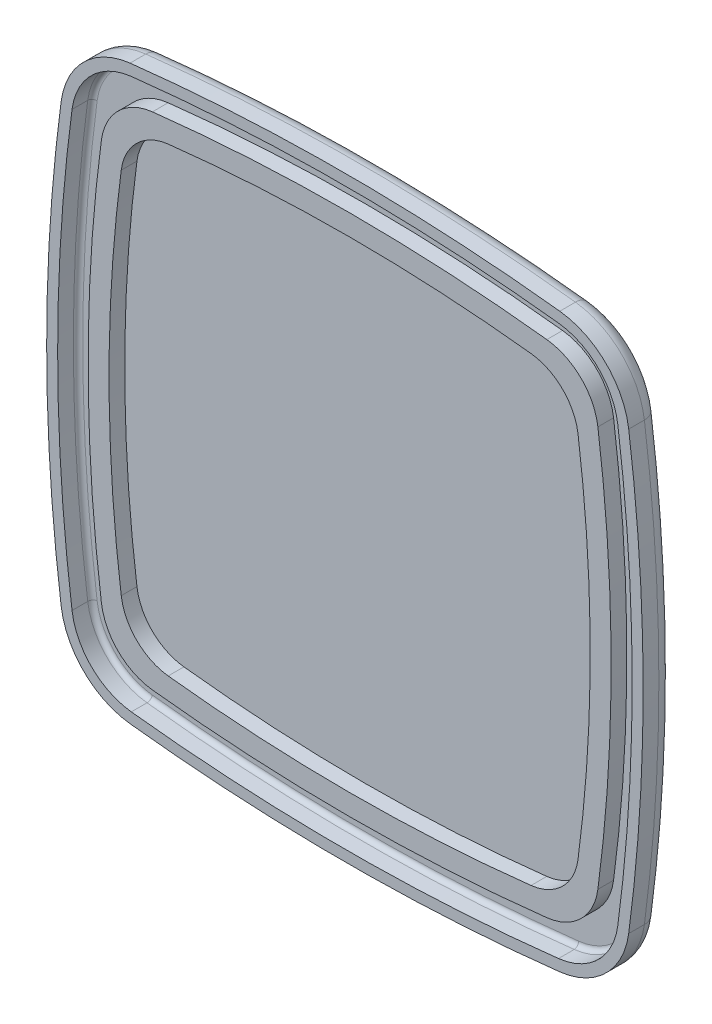
from build123d import *

# Parameters (mm, degrees)
IZIM1_W                      = 38
IZIM1_H                      = 38
Y_KSEKLIK_EKSTR_ZYON1_DEPTH  = 1
KES_EKSTR_ZYON1_DEPTH        = 3
KES_EKSTR_ZYON2_DEPTH        = 3
RADYUS1_R                    = 5
RADYUS2_R                    = 1
BO_ALTMA1_T                  = -0.7
Y_KSEKLIK_EKSTR_ZYON10_DEPTH = 1
KES_EKSTR_ZYON7_DEPTH        = 1


with BuildPart() as part:
    # Çizim1 → Yükseklik-Ekstrüzyon1 (new body, symmetric)
    with BuildSketch(Plane.XY):
        Rectangle(IZIM1_W, IZIM1_H)
    extrude(amount=Y_KSEKLIK_EKSTR_ZYON1_DEPTH, both=True)

    # Çizim2 → Kes-Ekstrüzyon1 (cut, through all)
    with BuildSketch(Plane.XY.offset(1)):
        with BuildLine():
            Line((19, 19), (0, 19))
            ThreePointArc((0, 19), (9.529559276, 18.624417499), (19, 17.5))
            Line((19, 17.5), (19, 19))
        make_face()
        with BuildLine():
            Line((0, 19), (-19, 19))
            Line((-19, 19), (-19, 17.5))
            ThreePointArc((-19, 17.5), (-9.529559276, 18.624417499), (0, 19))
        make_face()
        with BuildLine():
            ThreePointArc((0, -19), (-9.529559276, -18.624417499), (-19, -17.5))
            Line((-19, -17.5), (-19, -19))
            Line((-19, -19), (0, -19))
        make_face()
        with BuildLine():
            Line((19, -19), (19, -17.5))
            ThreePointArc((19, -17.5), (9.529559276, -18.624417499), (0, -19))
            Line((0, -19), (19, -19))
        make_face()
    extrude(amount=-KES_EKSTR_ZYON1_DEPTH, mode=Mode.SUBTRACT)

    # Çizim3 → Kes-Ekstrüzyon2 (cut, through all)
    with BuildSketch(Plane.XY.offset(1)):
        with BuildLine():
            Line((19, 0), (19, 17.5))
            ThreePointArc((19, 17.5), (18.250358245, 17.61670023), (17.5, 17.728701167))
            ThreePointArc((17.5, 17.728701167), (18.624331272, 8.896022216), (19, 0))
        make_face()
        with BuildLine():
            Line((19, -17.5), (19, 0))
            ThreePointArc((19, 0), (18.624331272, -8.896022216), (17.5, -17.728701167))
            ThreePointArc((17.5, -17.728701167), (18.250358245, -17.61670023), (19, -17.5))
        make_face()
        with BuildLine():
            ThreePointArc((-19, -17.5), (-18.250358245, -17.61670023), (-17.5, -17.728701167))
            ThreePointArc((-17.5, -17.728701167), (-18.624331272, -8.896022216), (-19, 0))
            Line((-19, 0), (-19, -17.5))
        make_face()
        with BuildLine():
            ThreePointArc((-19, 0), (-18.624331272, 8.896022216), (-17.5, 17.728701167))
            ThreePointArc((-17.5, 17.728701167), (-18.250358245, 17.61670023), (-19, 17.5))
            Line((-19, 17.5), (-19, 0))
        make_face()
    extrude(amount=-KES_EKSTR_ZYON2_DEPTH, mode=Mode.SUBTRACT)

    # Radyus1
    radyus1_edges = [part.edges().sort_by_distance(p)[0] for p in [
        (17.5, 17.728701167, 0),
        (17.5, -17.728701167, 0),
        (-17.5, -17.728701167, 0),
        (-17.5, 17.728701167, 0),
    ]]
    fillet(radyus1_edges, radius=RADYUS1_R)

    # Radyus2
    radyus2_edges = [part.edges().sort_by_distance(p)[0] for p in [
        (-19, 0, -1),
        (0, -19, -1),
        (0, 19, -1),
        (19, 0, -1),
        (16.62392767, 16.824874803, -1),
        (-16.62392767, 16.824874803, -1),
        (16.62392767, -16.824874803, -1),
        (-16.62392767, -16.824874803, -1),
    ]]
    fillet(radyus2_edges, radius=RADYUS2_R)

    # İç Boşaltma1
    bo_altma1_openings = [part.faces().sort_by_distance(p)[0] for p in [
        (0, 0, 1),
    ]]
    offset(amount=BO_ALTMA1_T, openings=bo_altma1_openings)


with BuildPart() as body_2:
    # Çizim10 → Yükseklik-Ekstrüzyon10 (new body)
    with BuildSketch(Plane.XY.offset(-0.3)):
        with BuildLine():
            ThreePointArc((12.563728068, 15.947604972), (0, 16.65999216), (-12.563728068, 15.947604972))
            ThreePointArc((-12.563728068, 15.947604972), (-14.738134647, 14.911702064), (-15.815114277, 12.757345157))
            ThreePointArc((-15.815114277, 12.757345157), (-16.65999216, 0), (-15.815114277, -12.757345157))
            ThreePointArc((-15.815114277, -12.757345157), (-14.738134647, -14.911702064), (-12.563728068, -15.947604972))
            ThreePointArc((-12.563728068, -15.947604972), (0, -16.65999216), (12.563728068, -15.947604972))
            ThreePointArc((12.563728068, -15.947604972), (14.738134647, -14.911702064), (15.815114277, -12.757345157))
            ThreePointArc((15.815114277, -12.757345157), (16.65999216, 0), (15.815114277, 12.757345157))
            ThreePointArc((15.815114277, 12.757345157), (14.738134647, 14.911702064), (12.563728068, 15.947604972))
        make_face()
    extrude(amount=Y_KSEKLIK_EKSTR_ZYON10_DEPTH)

    # Çizim15 → Kes-Ekstrüzyon7 (cut)
    with BuildSketch(Plane.XY.offset(0.7)):
        with BuildLine():
            ThreePointArc((14.549905135, 11.736757544), (13.559083875, 13.718765899), (11.558629822, 14.671796574))
            ThreePointArc((11.558629822, 14.671796574), (0, 15.327192787), (-11.558629822, 14.671796574))
            ThreePointArc((-11.558629822, 14.671796574), (-13.559083875, 13.718765899), (-14.549905135, 11.736757544))
            ThreePointArc((-14.549905135, 11.736757544), (-15.327192787, 0), (-14.549905135, -11.736757544))
            ThreePointArc((-14.549905135, -11.736757544), (-13.559083875, -13.718765899), (-11.558629822, -14.671796574))
            ThreePointArc((-11.558629822, -14.671796574), (0, -15.327192787), (11.558629822, -14.671796574))
            ThreePointArc((11.558629822, -14.671796574), (13.559083875, -13.718765899), (14.549905135, -11.736757544))
            ThreePointArc((14.549905135, -11.736757544), (15.327192787, 0), (14.549905135, 11.736757544))
        make_face()
    extrude(amount=-KES_EKSTR_ZYON7_DEPTH, mode=Mode.SUBTRACT)


solid = Compound([part.part, body_2.part])
